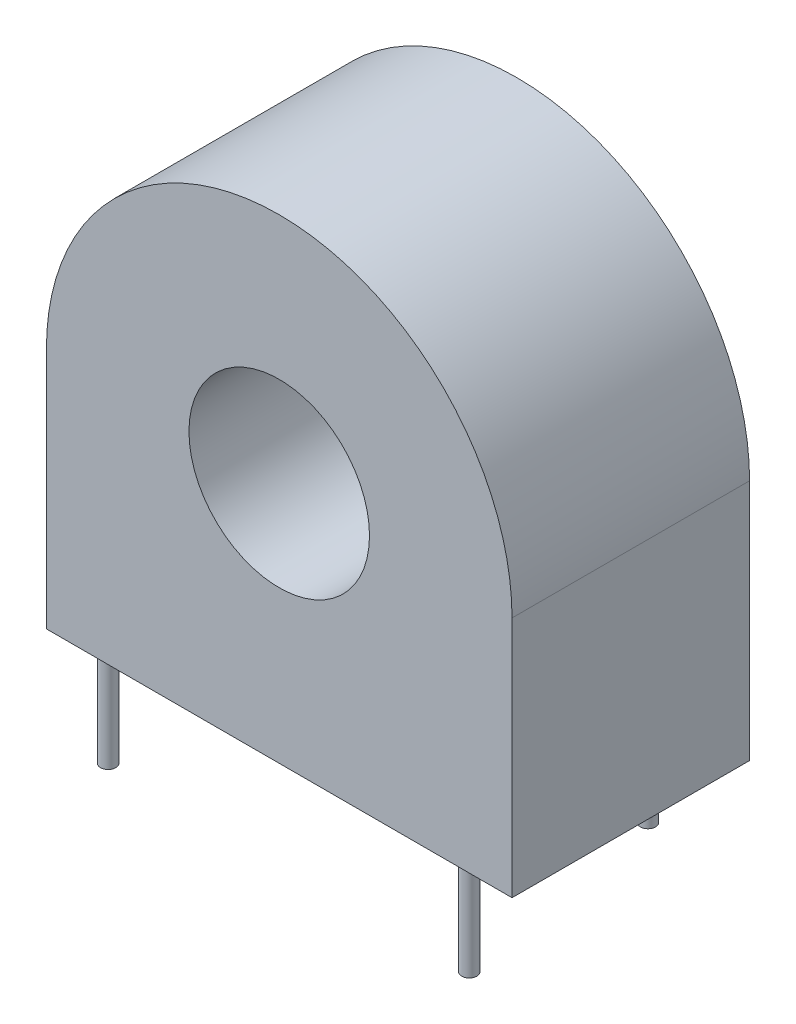
from build123d import *

# Parameters (mm, degrees)
SKETCH_1_R      = 4.75
EXTRUDE_1_DEPTH = 12.5
SKETCH_2_R      = 0.4
EXTRUDE_2_DEPTH = 5


with BuildPart() as part:
    # Эскиз1 → Бобышка-Вытянуть1 (new body)
    with BuildSketch(Plane.XY):
        with BuildLine():
            Line((12.25, -6.375), (-12.25, -6.375))
            Line((-12.25, -6.375), (-12.25, 6.375))
            ThreePointArc((-12.25, 6.375), (0, 18.625), (12.25, 6.375))
            Line((12.25, 6.375), (12.25, -6.375))
        make_face()
        with Locations((0, 6.375)):
            Circle(SKETCH_1_R, mode=Mode.SUBTRACT)
    extrude(amount=EXTRUDE_1_DEPTH)

    # Эскиз2 → Бобышка-Вытянуть2 (add)
    with BuildSketch(Plane.XZ.offset(6.375)):
        with Locations((7.4, 0.5)):
            Circle(SKETCH_2_R)
        with Locations((-7.4, 0.5)):
            Circle(SKETCH_2_R)
        with Locations((9.5, 12)):
            Circle(SKETCH_2_R)
        with Locations((-9.5, 12)):
            Circle(SKETCH_2_R)
    extrude(amount=EXTRUDE_2_DEPTH)


solid = part.part
